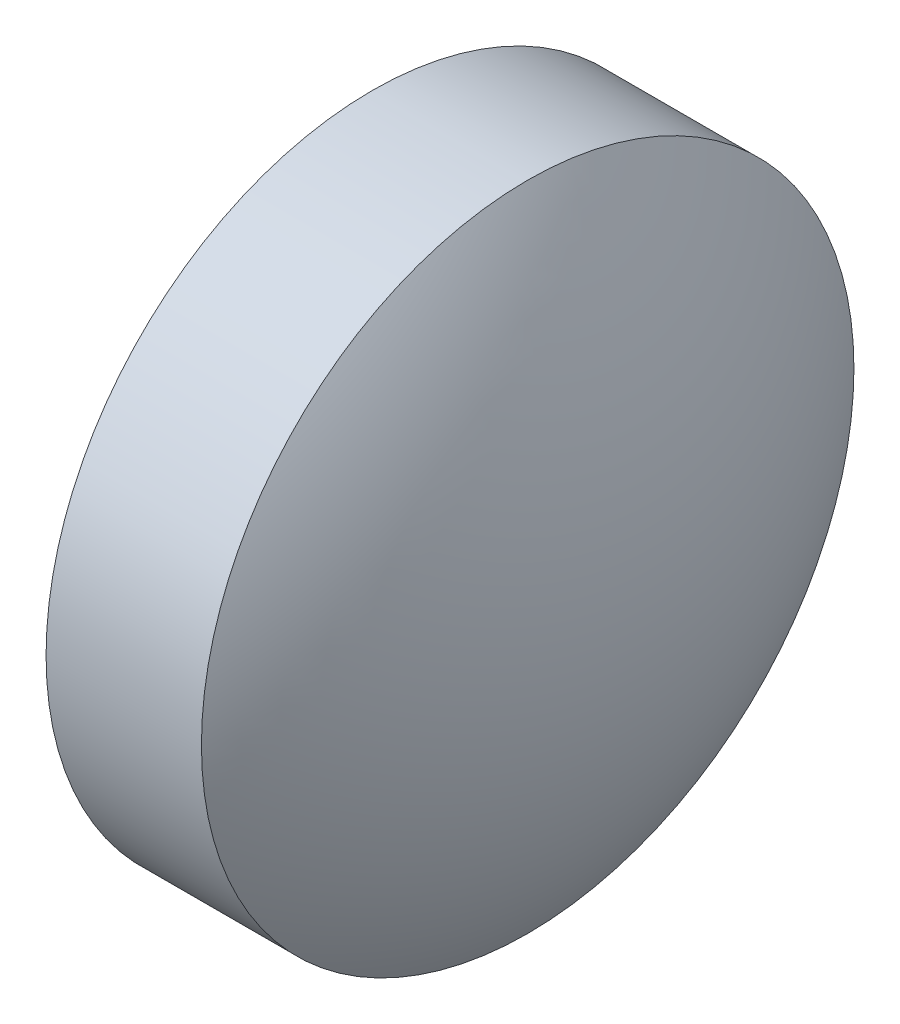
from build123d import *


with BuildPart() as part:
    # 草图2 → 旋转2 (revolve)
    with BuildSketch(Plane.XY):
        with BuildLine():
            Line((418.009837004, -21.677401607), (418.009837004, -18.527401607))
            Line((418.009837004, -18.527401607), (419.509837004, -18.527401607))
            ThreePointArc((419.509837004, -18.527401607), (420.209826043, -20.033769957), (420.449837004, -21.677401607))
            Line((420.449837004, -21.677401607), (418.009837004, -21.677401607))
        make_face()
    revolve(axis=Axis((417.149198915, -21.677401607, 0), (1, 0, 0)))


solid = part.part
